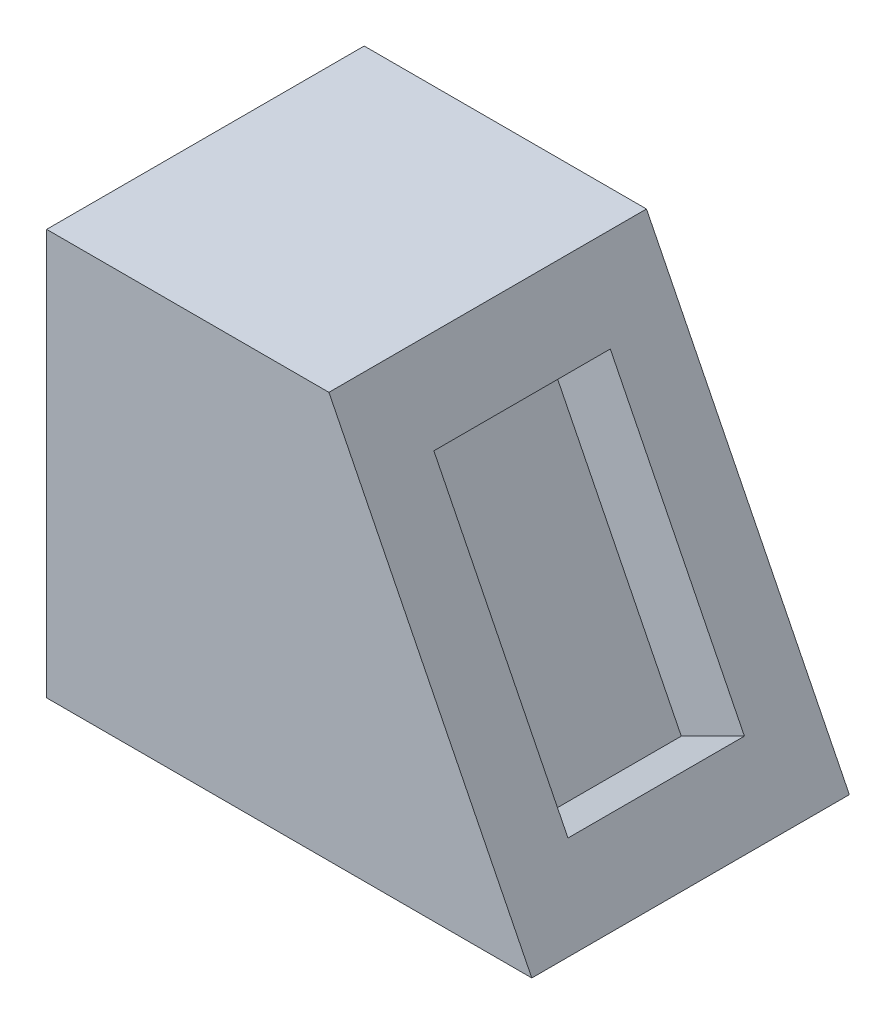
from build123d import *

# Parameters (mm, degrees)
BOSS_EXTRUDE1_DEPTH = 180
SKETCH3_W           = 100
SKETCH3_H           = 170
CUT_EXTRUDE4_DEPTH  = 50


with BuildPart() as part:
    # Sketch1 → Boss-Extrude1 (new body)
    with BuildSketch(Plane.XY):
        Polygon((0, 0), (275, 0), (160, 230), (0, 230), align=None)
    extrude(amount=-BOSS_EXTRUDE1_DEPTH)

    # Sketch3 → Cut-Extrude4 (cut)
    with BuildSketch(Plane(origin=(228.94427191, 114.472135955, 0), x_dir=(0, 0, -1), z_dir=(0.894427191, 0.447213595, 0))):
        with Locations((90, 5.590169944)):
            Rectangle(SKETCH3_W, SKETCH3_H)
    extrude(amount=-CUT_EXTRUDE4_DEPTH, mode=Mode.SUBTRACT)


solid = part.part
